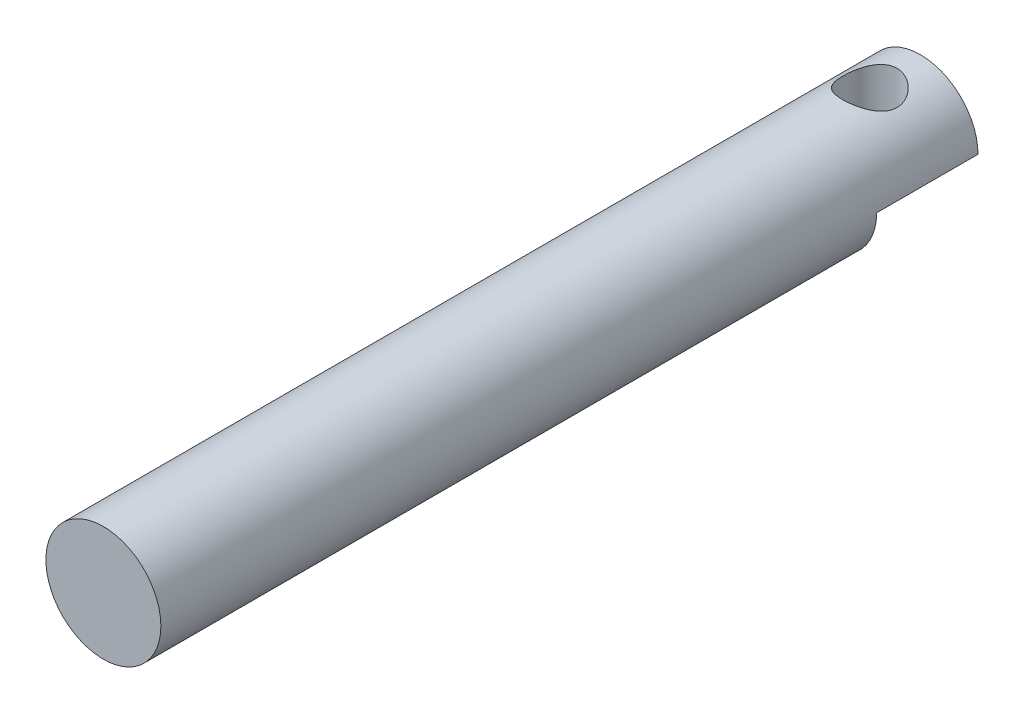
from build123d import *

# Parameters (mm, degrees)
SKETCH1_R           = 3.175
BOSS_EXTRUDE1_DEPTH = 45.12
SKETCH2_W           = 6.35
SKETCH2_H           = 5.59727822
CUT_EXTRUDE1_DEPTH  = 7
SKETCH3_R           = 1.5
CUT_EXTRUDE2_DEPTH  = 7


with BuildPart() as part:
    # Sketch1 → Boss-Extrude1 (new body)
    with BuildSketch(Plane.XY):
        Circle(SKETCH1_R)
    extrude(amount=BOSS_EXTRUDE1_DEPTH)

    # Sketch2 → Cut-Extrude1 (cut)
    with BuildSketch(Plane(origin=(0, 0, 0), x_dir=(1, 0, 0), z_dir=(0, 1, 0))):
        with Locations((0, -2.79863911)):
            Rectangle(SKETCH2_W, SKETCH2_H)
    extrude(amount=-CUT_EXTRUDE1_DEPTH, mode=Mode.SUBTRACT)

    # Sketch3 → Cut-Extrude2 (cut)
    with BuildSketch(Plane.XZ):
        with Locations((0, 2.79863911)):
            Circle(SKETCH3_R)
    extrude(amount=-CUT_EXTRUDE2_DEPTH, mode=Mode.SUBTRACT)


solid = part.part
